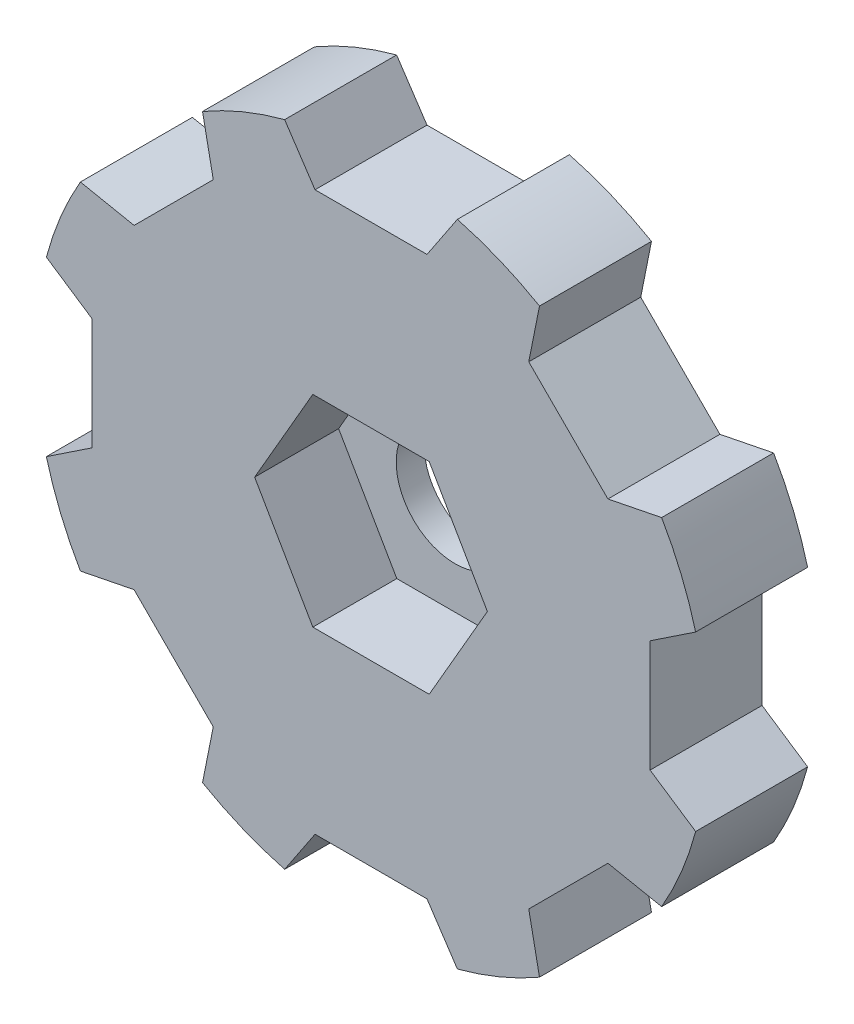
from build123d import *

# Parameters (mm, degrees)
SKETCH1_R           = 12
SKETCH1_R_2         = 2.1
BOSS_EXTRUDE1_DEPTH = 4
CUT_EXTRUDE1_DEPTH  = 3
CUT_EXTRUDE2_DEPTH  = 4
CIRPATTERN1_COUNT   = 8


with BuildPart() as part:
    # Sketch1 → Boss-Extrude1 (new body)
    with BuildSketch(Plane.XY):
        Circle(SKETCH1_R)
        Circle(SKETCH1_R_2, mode=Mode.SUBTRACT)
    extrude(amount=BOSS_EXTRUDE1_DEPTH)

    # Sketch2 → Cut-Extrude1 (cut)
    with BuildSketch(Plane.XY.offset(4)):
        Polygon((4.156921938, 0), (2.078460969, 3.6), (-2.078460969, 3.6), (-4.156921938, 0), (-2.078460969, -3.6), (2.078460969, -3.6), align=None)
    extrude(amount=-CUT_EXTRUDE1_DEPTH, mode=Mode.SUBTRACT)

    # Sketch3 → Cut-Extrude2 (cut)
    with BuildSketch(Plane.XY.offset(4)):
        Polygon((9.968896423, 2), (12.968896423, 4), (12.968896423, -4), (9.968896423, -2), align=None)
    cut_extrude2 = extrude(amount=-CUT_EXTRUDE2_DEPTH, mode=Mode.SUBTRACT)

    # CirPattern1: Cut-Extrude2 ×8 about axis
    cirpattern1_axis = Axis((0, 0, 0), (0, 0, 1))
    for i in range(1, CIRPATTERN1_COUNT):
        add(cut_extrude2.rotate(cirpattern1_axis, i * 360 / CIRPATTERN1_COUNT), mode=Mode.SUBTRACT)


solid = part.part
